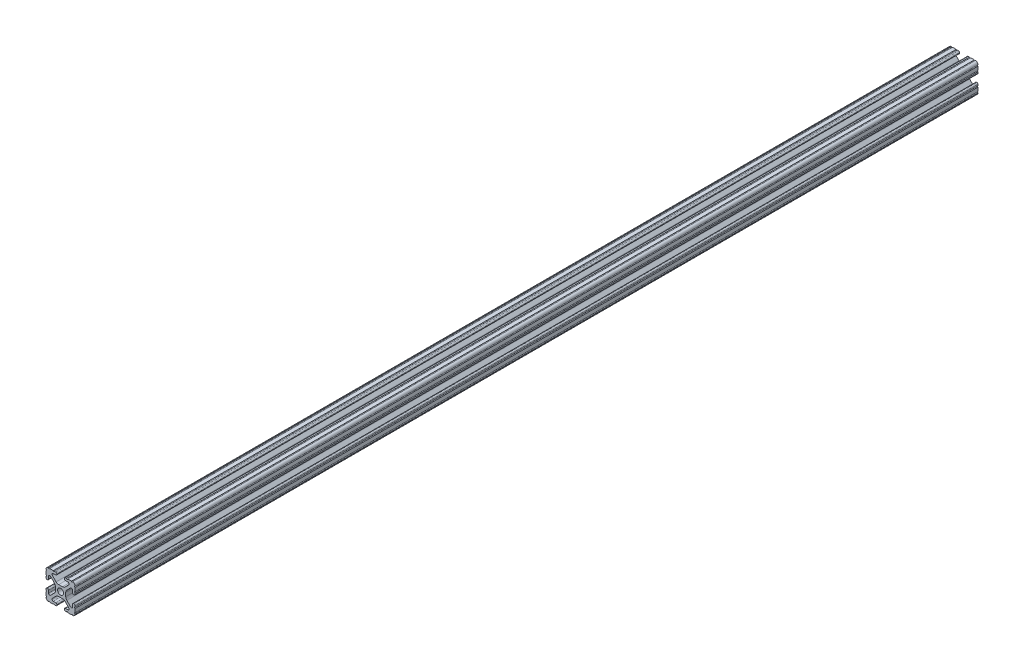
from build123d import *

# Parameters (mm, degrees)
SKETCH1_R               = 2.6035
BOSS_EXTRUDE1_DEPTH     = 393.7
SKETCH2_R               = 3.175
CUT_EXTRUDE1_DEPTH      = 9.1915
CUT_EXTRUDE1_DEPTH_BACK = 18.2085


with BuildPart() as part:
    # Sketch1 → Boss-Extrude1 (new body, symmetric)
    with BuildSketch(Plane.XY):
        with BuildLine():
            Line((-7.179650497, -8.645192506), (-3.952270251, -5.423690499))
            ThreePointArc((-3.952270251, -5.423690499), (-2.922936451, -4.736929036), (-1.709253557, -4.4958))
            Line((-1.709253557, -4.4958), (1.709253557, -4.4958))
            ThreePointArc((1.709253557, -4.4958), (2.922936451, -4.736929036), (3.952270251, -5.423690499))
            Line((3.952270251, -5.423690499), (7.179650497, -8.645192506))
            ThreePointArc((7.179650497, -8.645192506), (7.41473083, -9.822813117), (6.416408329, -10.4902))
            Line((6.416408329, -10.4902), (4.287512407, -10.4902))
            ThreePointArc((4.287512407, -10.4902), (3.54574862, -10.79744862), (3.2385, -11.539212407))
            Line((3.2385, -11.539212407), (3.2385, -11.650987593))
            ThreePointArc((3.2385, -11.650987593), (3.54574862, -12.39275138), (4.287512407, -12.7))
            Line((4.287512407, -12.7), (5.317126718, -12.7))
            ThreePointArc((5.317126718, -12.7), (5.825126718, -12.192), (6.333126718, -12.7))
            Line((6.333126718, -12.7), (9.550443118, -12.7))
            ThreePointArc((9.550443118, -12.7), (10.058366869, -12.192000006), (10.566443095, -12.699847501))
            ThreePointArc((10.566443095, -12.699847501), (12.082537762, -12.08250727), (12.699846982, -10.566399977))
            ThreePointArc((12.699846982, -10.566399977), (12.192000006, -10.058323491), (12.7, -9.5504))
            Line((12.7, -9.5504), (12.7, -6.3330836))
            ThreePointArc((12.7, -6.3330836), (12.192, -5.8250836), (12.7, -5.3170836))
            Line((12.7, -5.3170836), (12.7, -4.287469289))
            ThreePointArc((12.7, -4.287469289), (12.39275138, -3.545705502), (11.650987593, -3.238456882))
            Line((11.650987593, -3.238456882), (11.539212407, -3.238456882))
            ThreePointArc((11.539212407, -3.238456882), (10.79744862, -3.545705502), (10.4902, -4.287469289))
            Line((10.4902, -4.287469289), (10.4902, -6.402089023))
            ThreePointArc((10.4902, -6.402089023), (9.856505071, -7.351067942), (8.737131347, -7.129408934))
            Line((8.737131347, -7.129408934), (5.441005833, -3.840816462))
            ThreePointArc((5.441005833, -3.840816462), (4.750877967, -2.809883091), (4.5085, -1.593185507))
            Line((4.5085, -1.593185507), (4.5085, 1.593185507))
            ThreePointArc((4.5085, 1.593185507), (4.750877967, 2.809883091), (5.441005833, 3.840816462))
            Line((5.441005833, 3.840816462), (8.737131347, 7.129408934))
            ThreePointArc((8.737131347, 7.129408934), (9.856505071, 7.351067942), (10.4902, 6.402089023))
            Line((10.4902, 6.402089023), (10.4902, 4.287469289))
            ThreePointArc((10.4902, 4.287469289), (10.79744862, 3.545705502), (11.539212407, 3.238456882))
            Line((11.539212407, 3.238456882), (11.650987593, 3.238456882))
            ThreePointArc((11.650987593, 3.238456882), (12.39275138, 3.545705502), (12.7, 4.287469289))
            Line((12.7, 4.287469289), (12.7, 5.3170836))
            ThreePointArc((12.7, 5.3170836), (12.192, 5.8250836), (12.7, 6.3330836))
            Line((12.7, 6.3330836), (12.7, 9.5504))
            ThreePointArc((12.7, 9.5504), (12.192000006, 10.058323491), (12.699846982, 10.566399977))
            ThreePointArc((12.699846982, 10.566399977), (12.082537762, 12.08250727), (10.566443095, 12.699847501))
            ThreePointArc((10.566443095, 12.699847501), (10.058366869, 12.192000006), (9.550443118, 12.7))
            Line((9.550443118, 12.7), (6.333126718, 12.7))
            ThreePointArc((6.333126718, 12.7), (5.825126718, 12.192), (5.317126718, 12.7))
            Line((5.317126718, 12.7), (4.287512407, 12.7))
            ThreePointArc((4.287512407, 12.7), (3.54574862, 12.39275138), (3.2385, 11.650987593))
            Line((3.2385, 11.650987593), (3.2385, 11.539212407))
            ThreePointArc((3.2385, 11.539212407), (3.54574862, 10.79744862), (4.287512407, 10.4902))
            Line((4.287512407, 10.4902), (6.476788598, 10.4902))
            ThreePointArc((6.476788598, 10.4902), (7.432222385, 9.85140422), (7.207036008, 8.724370562))
            Line((7.207036008, 8.724370562), (3.898272566, 5.423169045))
            ThreePointArc((3.898272566, 5.423169045), (2.869120213, 4.736787962), (1.655778399, 4.4958))
            Line((1.655778399, 4.4958), (-1.655778399, 4.4958))
            ThreePointArc((-1.655778399, 4.4958), (-2.869120213, 4.736787962), (-3.898272566, 5.423169045))
            Line((-3.898272566, 5.423169045), (-7.207036008, 8.724370562))
            ThreePointArc((-7.207036008, 8.724370562), (-7.432222385, 9.85140422), (-6.476788598, 10.4902))
            Line((-6.476788598, 10.4902), (-4.287512407, 10.4902))
            ThreePointArc((-4.287512407, 10.4902), (-3.54574862, 10.79744862), (-3.2385, 11.539212407))
            Line((-3.2385, 11.539212407), (-3.2385, 11.650987593))
            ThreePointArc((-3.2385, 11.650987593), (-3.54574862, 12.39275138), (-4.287512407, 12.7))
            Line((-4.287512407, 12.7), (-5.317126718, 12.7))
            ThreePointArc((-5.317126718, 12.7), (-5.825126718, 12.192), (-6.333126718, 12.7))
            Line((-6.333126718, 12.7), (-9.550443118, 12.7))
            ThreePointArc((-9.550443118, 12.7), (-10.058366869, 12.192000006), (-10.566443095, 12.699847501))
            ThreePointArc((-10.566443095, 12.699847501), (-12.082537762, 12.08250727), (-12.699846982, 10.566399977))
            ThreePointArc((-12.699846982, 10.566399977), (-12.192000006, 10.058323491), (-12.7, 9.5504))
            Line((-12.7, 9.5504), (-12.7, 6.3330836))
            ThreePointArc((-12.7, 6.3330836), (-12.192, 5.8250836), (-12.7, 5.3170836))
            Line((-12.7, 5.3170836), (-12.7, 4.287469289))
            ThreePointArc((-12.7, 4.287469289), (-12.39275138, 3.545705502), (-11.650987593, 3.238456882))
            Line((-11.650987593, 3.238456882), (-11.539212407, 3.238456882))
            ThreePointArc((-11.539212407, 3.238456882), (-10.79744862, 3.545705502), (-10.4902, 4.287469289))
            Line((-10.4902, 4.287469289), (-10.4902, 6.402089023))
            ThreePointArc((-10.4902, 6.402089023), (-9.856505071, 7.351067942), (-8.737131347, 7.129408934))
            Line((-8.737131347, 7.129408934), (-5.441005833, 3.840816462))
            ThreePointArc((-5.441005833, 3.840816462), (-4.750877967, 2.809883091), (-4.5085, 1.593185507))
            Line((-4.5085, 1.593185507), (-4.5085, -1.593185507))
            ThreePointArc((-4.5085, -1.593185507), (-4.750877967, -2.809883091), (-5.441005833, -3.840816462))
            Line((-5.441005833, -3.840816462), (-8.737131347, -7.129408934))
            ThreePointArc((-8.737131347, -7.129408934), (-9.856505071, -7.351067942), (-10.4902, -6.402089023))
            Line((-10.4902, -6.402089023), (-10.4902, -4.287469289))
            ThreePointArc((-10.4902, -4.287469289), (-10.79744862, -3.545705502), (-11.539212407, -3.238456882))
            Line((-11.539212407, -3.238456882), (-11.650987593, -3.238456882))
            ThreePointArc((-11.650987593, -3.238456882), (-12.39275138, -3.545705502), (-12.7, -4.287469289))
            Line((-12.7, -4.287469289), (-12.7, -5.3170836))
            ThreePointArc((-12.7, -5.3170836), (-12.192, -5.8250836), (-12.7, -6.3330836))
            Line((-12.7, -6.3330836), (-12.7, -9.5504))
            ThreePointArc((-12.7, -9.5504), (-12.192000006, -10.058323491), (-12.699846982, -10.566399977))
            ThreePointArc((-12.699846982, -10.566399977), (-12.082537762, -12.08250727), (-10.566443095, -12.699847501))
            ThreePointArc((-10.566443095, -12.699847501), (-10.058366869, -12.192000006), (-9.550443118, -12.7))
            Line((-9.550443118, -12.7), (-6.333126718, -12.7))
            ThreePointArc((-6.333126718, -12.7), (-5.825126718, -12.192), (-5.317126718, -12.7))
            Line((-5.317126718, -12.7), (-4.287512407, -12.7))
            ThreePointArc((-4.287512407, -12.7), (-3.54574862, -12.39275138), (-3.2385, -11.650987593))
            Line((-3.2385, -11.650987593), (-3.2385, -11.539212407))
            ThreePointArc((-3.2385, -11.539212407), (-3.54574862, -10.79744862), (-4.287512407, -10.4902))
            Line((-4.287512407, -10.4902), (-6.416408329, -10.4902))
            ThreePointArc((-6.416408329, -10.4902), (-7.41473083, -9.822813117), (-7.179650497, -8.645192506))
        make_face()
        Circle(SKETCH1_R, mode=Mode.SUBTRACT)
    extrude(amount=BOSS_EXTRUDE1_DEPTH, both=True)

    # Sketch2 → Cut-Extrude1 (cut, two sides)
    with BuildSketch(Plane(origin=(4.5085, 0, 0), x_dir=(0, 0, -1), z_dir=(1, 0, 0))) as cut_extrude1_sk:
        with Locations((-279.4, 0)):
            Circle(SKETCH2_R)
        with Locations((279.4, 0)):
            Circle(SKETCH2_R)
        with Locations((-12.7, 0)):
            Circle(SKETCH2_R)
        with Locations((12.7, 0)):
            Circle(SKETCH2_R)
    extrude(amount=CUT_EXTRUDE1_DEPTH, mode=Mode.SUBTRACT)
    extrude(cut_extrude1_sk.sketch, amount=-CUT_EXTRUDE1_DEPTH_BACK, mode=Mode.SUBTRACT)


solid = part.part
